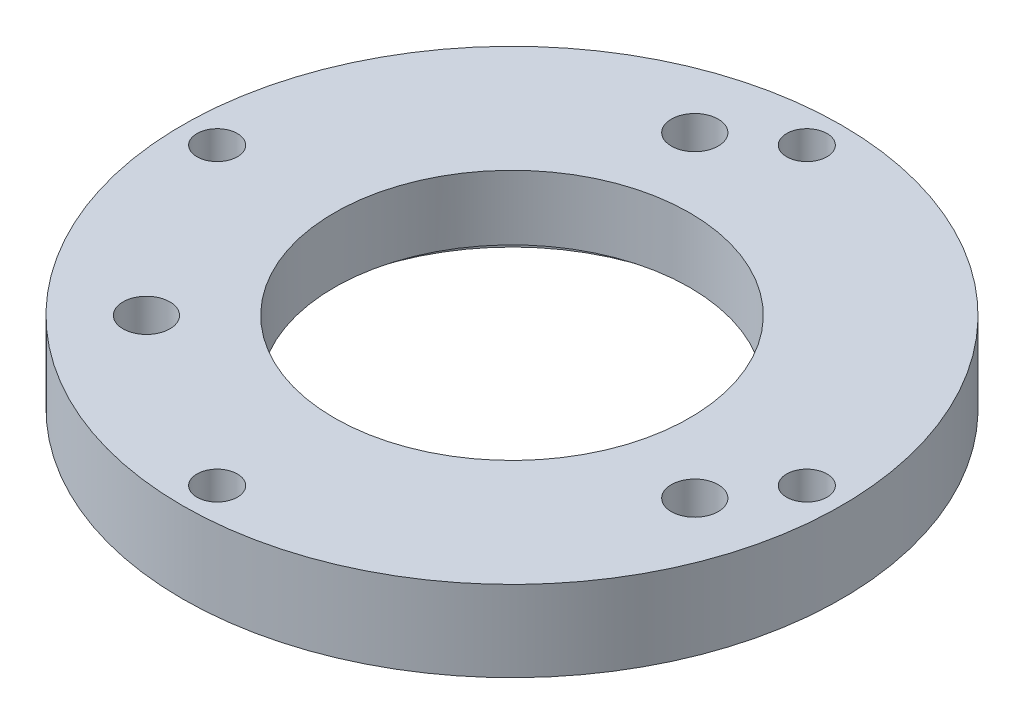
from build123d import *

# Parameters (mm, degrees)
SKETCH_1_R                    = 20.4
SKETCH_1_R_2                  = 11
EXTRUDE_1_DEPTH               = 5
M3X0_51_D                     = 2.5
HOLE_WIZARD_M2_51_D           = 2.9
HOLE_WIZARD_M2_51_CBORE_D     = 5.5
HOLE_WIZARD_M2_51_CBORE_DEPTH = 2.5
SKETCH_9_R                    = 12.25
CUT_EXTRUDE_1_DEPTH           = 1


with BuildPart() as part:
    # Эскиз1 → Бобышка-Вытянуть1 (new body)
    with BuildSketch(Plane(origin=(0, 0, 0), x_dir=(1, 0, 0), z_dir=(0, 1, 0))):
        Circle(SKETCH_1_R)
        Circle(SKETCH_1_R_2, mode=Mode.SUBTRACT)
    extrude(amount=EXTRUDE_1_DEPTH)

    # Отверстие обработанное метчиком M3x0.51 (through all)
    with Locations(Plane(origin=(0, 5, 0), x_dir=(1, 0, 0), z_dir=(0, 1, 0))):
        with Locations((-18.25, 0), (0, 18.25), (18.25, 0), (0, -18.25)):
            Hole(M3X0_51_D / 2)

    # Цековка для винта с внутренним шестигранником M2.51 (through all)
    with Locations(Plane(origin=(0, 0, 0), x_dir=(-1, 0, 0), z_dir=(0, -1, 0))):
        with Locations((11.313708499, -11.313708499), (4.141104722, 15.454813221), (-15.454813221, -4.141104722)):
            CounterBoreHole(HOLE_WIZARD_M2_51_D / 2, HOLE_WIZARD_M2_51_CBORE_D / 2, HOLE_WIZARD_M2_51_CBORE_DEPTH)

    # Эскиз9 → Вырез-Вытянуть1 (cut)
    with BuildSketch(Plane.XZ):
        Circle(SKETCH_9_R)
    extrude(amount=-CUT_EXTRUDE_1_DEPTH, mode=Mode.SUBTRACT)


solid = part.part
